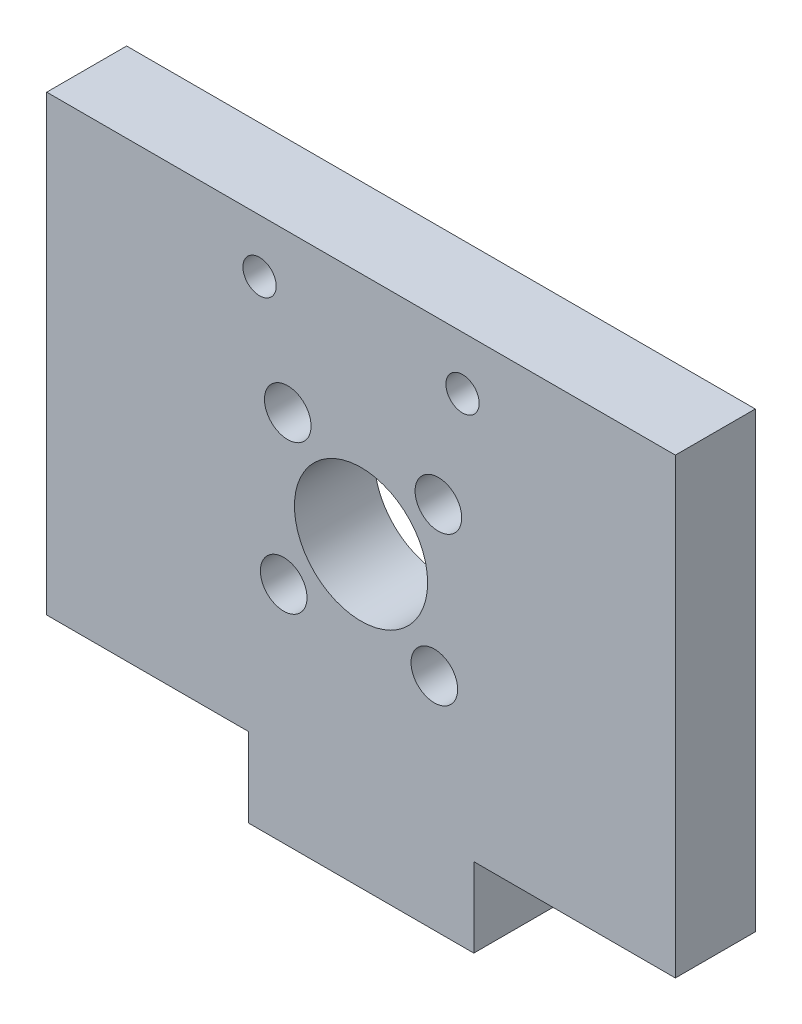
from build123d import *

# Parameters (mm, degrees)
SKETCH1_R           = 5
SKETCH1_R_2         = 1.75
BOSS_EXTRUDE1_DEPTH = 6
CUT_EXTRUDE1_REACH  = 8
SKETCH2_R           = 1.25


with BuildPart() as part:
    # Sketch1 → Boss-Extrude1 (new body)
    with BuildSketch(Plane.XY):
        Polygon((348.916937196, 226.998518154), (348.916937196, 260.998518154), (301.716937196, 260.998518154), (301.716937196, 226.998518154), (316.850270529, 226.998518154), (316.850270529, 221.04907787), (333.783603862, 221.04907787), (333.783603862, 226.998518154), align=None)
        with Locations((325.316937196, 243.398518154)):
            Circle(SKETCH1_R, mode=Mode.SUBTRACT)
        with Locations((331.123946249, 248.901121707)):
            Circle(SKETCH1_R_2, mode=Mode.SUBTRACT)
        with Locations((319.814333643, 249.205527207)):
            Circle(SKETCH1_R_2, mode=Mode.SUBTRACT)
        with Locations((319.509928143, 237.895914601)):
            Circle(SKETCH1_R_2, mode=Mode.SUBTRACT)
        with Locations((330.819540748, 237.591509101)):
            Circle(SKETCH1_R_2, mode=Mode.SUBTRACT)
    extrude(amount=BOSS_EXTRUDE1_DEPTH)

    # Sketch2 → Cut-Extrude1 (cut, up to next)
    with BuildSketch(Plane.XY.offset(6), mode=Mode.PRIVATE) as cut_extrude1_sk1:
        with Locations((317.696937196, 256.998518154)):
            Circle(SKETCH2_R)
    cut_extrude1_tool1 = extrude(cut_extrude1_sk1.sketch, amount=-CUT_EXTRUDE1_REACH, mode=Mode.PRIVATE) & part.part
    add(cut_extrude1_tool1.solids().sort_by_distance((317.696937, 256.998518, 6))[0], mode=Mode.SUBTRACT)
    # Sketch2 → Cut-Extrude1 (cut, up to next)
    with BuildSketch(Plane.XY.offset(6), mode=Mode.PRIVATE) as cut_extrude1_sk2:
        with Locations((332.936937196, 256.998518154)):
            Circle(SKETCH2_R)
    cut_extrude1_tool2 = extrude(cut_extrude1_sk2.sketch, amount=-CUT_EXTRUDE1_REACH, mode=Mode.PRIVATE) & part.part
    add(cut_extrude1_tool2.solids().sort_by_distance((332.936937, 256.998518, 6))[0], mode=Mode.SUBTRACT)


solid = part.part
